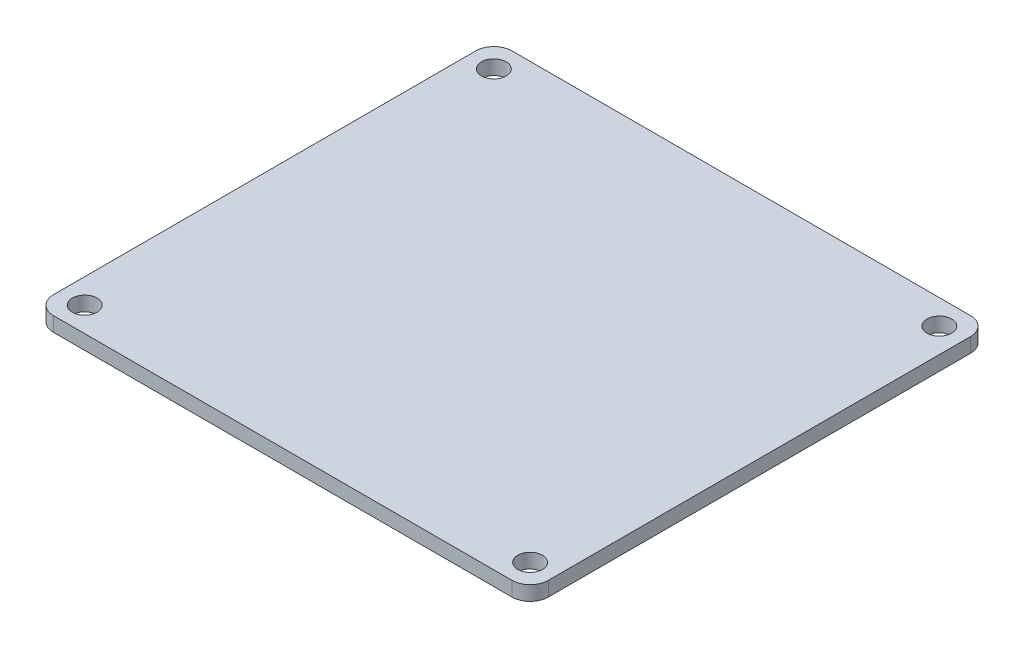
from build123d import *

# Parameters (mm, degrees)
SKETCH_1_R      = 1.7
EXTRUDE_2_DEPTH = 2


with BuildPart() as part:
    # ｽｹｯﾁ1 → ﾎﾞｽ - 押し出し2 (new body)
    with BuildSketch(Plane(origin=(0, 0, 0), x_dir=(1, 0, 0), z_dir=(0, 1, 0))):
        with BuildLine():
            Line((31.6, 31.6), (-31.6, 31.6))
            ThreePointArc((-31.6, 31.6), (-33.367766953, 30.867766953), (-34.1, 29.1))
            Line((-34.1, 29.1), (-34.1, -29.1))
            ThreePointArc((-34.1, -29.1), (-33.367766953, -30.867766953), (-31.6, -31.6))
            Line((-31.6, -31.6), (31.6, -31.6))
            ThreePointArc((31.6, -31.6), (33.367766953, -30.867766953), (34.1, -29.1))
            Line((34.1, -29.1), (34.1, 29.1))
            ThreePointArc((34.1, 29.1), (33.367766953, 30.867766953), (31.6, 31.6))
        make_face()
        with Locations((-30.7, 28.2)):
            Circle(SKETCH_1_R, mode=Mode.SUBTRACT)
        with Locations((30.7, 28.2)):
            Circle(SKETCH_1_R, mode=Mode.SUBTRACT)
        with Locations((-30.7, -28.2)):
            Circle(SKETCH_1_R, mode=Mode.SUBTRACT)
        with Locations((30.7, -28.2)):
            Circle(SKETCH_1_R, mode=Mode.SUBTRACT)
    extrude(amount=EXTRUDE_2_DEPTH)


solid = part.part
